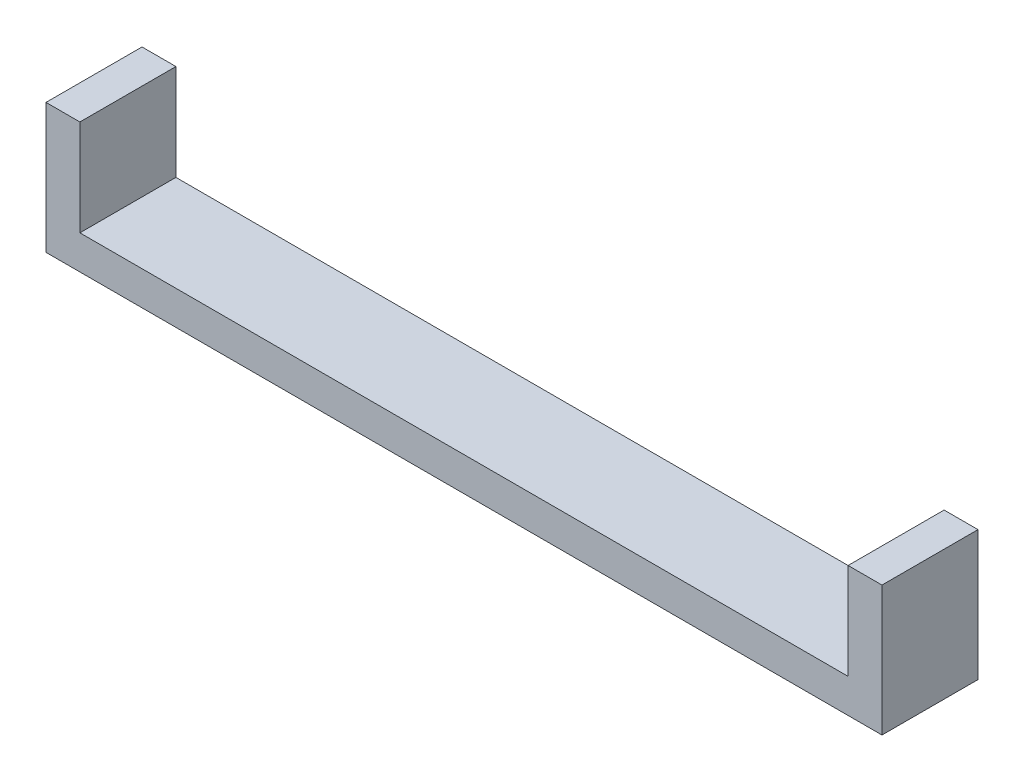
from build123d import *

# Parameters (mm, degrees)
SKETCH1_W            = 8.5
SKETCH1_H            = 8.5
BOSS_EXTRUDE1_DEPTH  = 5
SKETCH2_W            = 8.5
SKETCH2_H            = 8.5
BOSS_EXTRUDE2_DEPTH  = 2
SKETCH3_R            = 1.5
CUT_EXTRUDE1_DEPTH   = 2
SKETCH4_W            = 82
SKETCH4_H            = 8.5
BOSS_EXTRUDE3_DEPTH  = 3
SKETCH5_W            = 7
SKETCH5_H            = 8.5
BOSS_EXTRUDE4_DEPTH  = 8.5
CUT_EXTRUDE2_DEPTH   = 5
SKETCH7_R            = 1.5
CUT_EXTRUDE3_DEPTH   = 5
CUT_EXTRUDE4_DEPTH   = 10
SKETCH9_W            = 8.5
SKETCH9_H            = 8.5
SKETCH9_R            = 1.5
BOSS_EXTRUDE5_DEPTH  = 2
CUT_EXTRUDE5_DEPTH   = 2
SKETCH11_W           = 8.5
SKETCH11_H           = 8.5
SKETCH11_R           = 1.5
BOSS_EXTRUDE6_DEPTH  = 2
BOSS_EXTRUDE7_DEPTH  = 5
BOSS_EXTRUDE8_DEPTH  = 5
SKETCH14_W           = 8.5
SKETCH14_H           = 11.5
CUT_EXTRUDE6_DEPTH   = 4
SKETCH15_W           = 8.5
SKETCH15_H           = 11.5
CUT_EXTRUDE7_DEPTH   = 4
SKETCH16_R           = 1.5
CUT_EXTRUDE8_DEPTH   = 4
SKETCH17_R           = 1.5
CUT_EXTRUDE9_DEPTH   = 4
SKETCH19_W           = 8.5
SKETCH19_H           = 8.5
BOSS_EXTRUDE9_DEPTH  = 3
SKETCH20_W           = 8.5
SKETCH20_H           = 8.5
BOSS_EXTRUDE10_DEPTH = 3


with BuildPart() as part:
    # Sketch1 → Boss-Extrude1 (new body)
    with BuildSketch(Plane(origin=(0, 0, 0), x_dir=(0, 0, -1), z_dir=(1, 0, 0))):
        Rectangle(SKETCH1_W, SKETCH1_H)
        Polygon((1.58771324, 2.75), (-1.58771324, 2.75), (-3.175426481, 0), (-1.58771324, -2.75), (1.58771324, -2.75), (3.175426481, 0), align=None, mode=Mode.SUBTRACT)
    extrude(amount=BOSS_EXTRUDE1_DEPTH)

    # Sketch2 → Boss-Extrude2 (add)
    with BuildSketch(Plane.ZY):
        Rectangle(SKETCH2_W, SKETCH2_H)
    extrude(amount=BOSS_EXTRUDE2_DEPTH)

    # Sketch3 → Cut-Extrude1 (cut)
    with BuildSketch(Plane(origin=(0, 0, 0), x_dir=(0, 0, -1), z_dir=(1, 0, 0))):
        Circle(SKETCH3_R)
    extrude(amount=-CUT_EXTRUDE1_DEPTH, mode=Mode.SUBTRACT)

    # Sketch4 → Boss-Extrude3 (add)
    with BuildSketch(Plane.XZ.offset(4.25)):
        with Locations((39, 0)):
            Rectangle(SKETCH4_W, SKETCH4_H)
    extrude(amount=BOSS_EXTRUDE3_DEPTH)

    # Sketch5 → Boss-Extrude4 (add)
    with BuildSketch(Plane(origin=(0, -4.25, 0), x_dir=(1, 0, 0), z_dir=(0, 1, 0))):
        with Locations((76.5, 0)):
            Rectangle(SKETCH5_W, SKETCH5_H)
    extrude(amount=BOSS_EXTRUDE4_DEPTH)

    # Sketch6 → Cut-Extrude2 (cut)
    with BuildSketch(Plane.ZY.offset(-73)):
        Polygon((3.175426481, 0), (1.58771324, 2.75), (-1.58771324, 2.75), (-3.175426481, 0), (-1.58771324, -2.75), (1.58771324, -2.75), align=None)
    extrude(amount=-CUT_EXTRUDE2_DEPTH, mode=Mode.SUBTRACT)

    # Sketch7 → Cut-Extrude3 (cut)
    with BuildSketch(Plane.ZY.offset(-78)):
        Circle(SKETCH7_R)
    extrude(amount=-CUT_EXTRUDE3_DEPTH, mode=Mode.SUBTRACT)

    # Sketch8 → Cut-Extrude4 (cut)
    with BuildSketch(Plane.ZY.offset(2)):
        Polygon((-1.58771324, 2.75), (1.58771324, 2.75), (3.175426481, 0), (1.58771324, -2.75), (-1.58771324, -2.75), (-3.175426481, 0), align=None)
    extrude(amount=-CUT_EXTRUDE4_DEPTH, mode=Mode.SUBTRACT)

    # Sketch9 → Boss-Extrude5 (add)
    with BuildSketch(Plane(origin=(5, 0, 0), x_dir=(0, 0, -1), z_dir=(1, 0, 0))):
        Rectangle(SKETCH9_W, SKETCH9_H)
        Circle(SKETCH9_R, mode=Mode.SUBTRACT)
    extrude(amount=-BOSS_EXTRUDE5_DEPTH)

    # Sketch10 → Cut-Extrude5 (cut)
    with BuildSketch(Plane(origin=(80, 0, 0), x_dir=(0, 0, -1), z_dir=(1, 0, 0))):
        Polygon((-3.175426481, 0), (-1.58771324, 2.75), (1.58771324, 2.75), (3.175426481, 0), (1.58771324, -2.75), (-1.58771324, -2.75), align=None)
    extrude(amount=-CUT_EXTRUDE5_DEPTH, mode=Mode.SUBTRACT)

    # Sketch11 → Boss-Extrude6 (add)
    with BuildSketch(Plane.ZY.offset(-73)):
        Rectangle(SKETCH11_W, SKETCH11_H)
        Circle(SKETCH11_R, mode=Mode.SUBTRACT)
    extrude(amount=-BOSS_EXTRUDE6_DEPTH)

    # Sketch12 → Boss-Extrude7 (add)
    with BuildSketch(Plane.ZY.offset(-3)):
        Polygon((-3.175426481, 0), (-1.58771324, 2.75), (1.58771324, 2.75), (3.175426481, 0), (1.58771324, -2.75), (-1.58771324, -2.75), align=None)
    extrude(amount=BOSS_EXTRUDE7_DEPTH)

    # Sketch13 → Boss-Extrude8 (add)
    with BuildSketch(Plane(origin=(75, 0, 0), x_dir=(0, 0, -1), z_dir=(1, 0, 0))):
        Polygon((-1.58771324, 2.75), (-3.175426481, 0), (-1.58771324, -2.75), (1.58771324, -2.75), (3.175426481, 0), (1.58771324, 2.75), align=None)
    extrude(amount=BOSS_EXTRUDE8_DEPTH)

    # Sketch14 → Cut-Extrude6 (cut)
    with BuildSketch(Plane.ZY.offset(2)):
        with Locations((0, -1.5)):
            Rectangle(SKETCH14_W, SKETCH14_H)
    extrude(amount=-CUT_EXTRUDE6_DEPTH, mode=Mode.SUBTRACT)

    # Sketch15 → Cut-Extrude7 (cut)
    with BuildSketch(Plane(origin=(80, 0, 0), x_dir=(0, 0, -1), z_dir=(1, 0, 0))):
        with Locations((0, -1.5)):
            Rectangle(SKETCH15_W, SKETCH15_H)
    extrude(amount=-CUT_EXTRUDE7_DEPTH, mode=Mode.SUBTRACT)

    # Sketch16 → Cut-Extrude8 (cut)
    with BuildSketch(Plane(origin=(5, 0, 0), x_dir=(0, 0, -1), z_dir=(1, 0, 0))):
        Circle(SKETCH16_R)
    extrude(amount=-CUT_EXTRUDE8_DEPTH, mode=Mode.SUBTRACT)

    # Sketch17 → Cut-Extrude9 (cut)
    with BuildSketch(Plane.ZY.offset(-75)):
        Circle(SKETCH17_R)
    extrude(amount=-CUT_EXTRUDE9_DEPTH, mode=Mode.SUBTRACT)

    # Sketch19 → Boss-Extrude9 (add)
    with BuildSketch(Plane(origin=(5, 0, 0), x_dir=(0, 0, -1), z_dir=(1, 0, 0))):
        Rectangle(SKETCH19_W, SKETCH19_H)
    extrude(amount=-BOSS_EXTRUDE9_DEPTH)

    # Sketch20 → Boss-Extrude10 (add)
    with BuildSketch(Plane.ZY.offset(-73)):
        Rectangle(SKETCH20_W, SKETCH20_H)
    extrude(amount=-BOSS_EXTRUDE10_DEPTH)


solid = part.part
